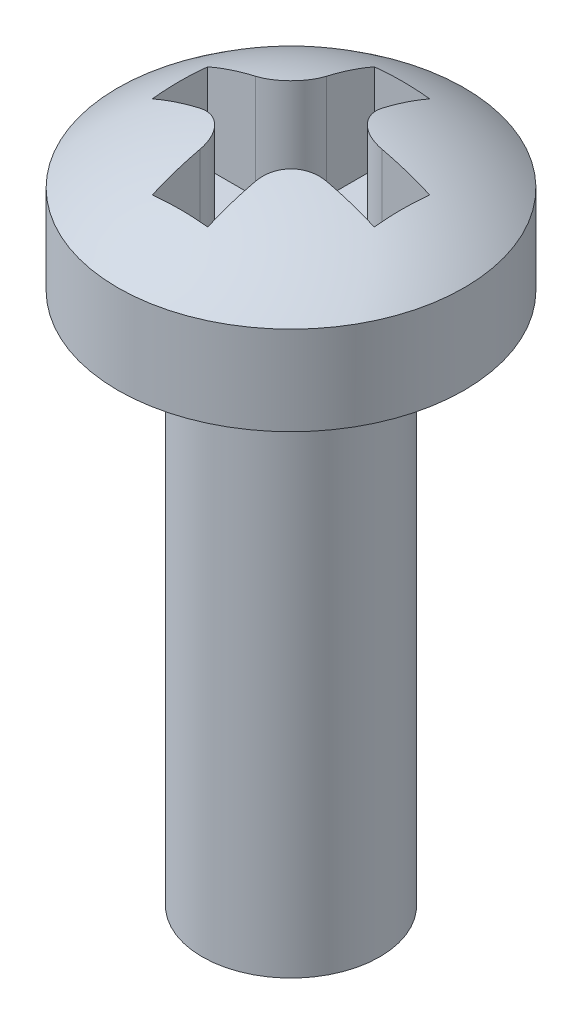
from build123d import *

# Parameters (mm, degrees)
SKETCH1_R           = 2
BOSS_EXTRUDE1_DEPTH = 12
SKETCH5_R           = 3.9
BOSS_EXTRUDE2_DEPTH = 2
CUT_EXTRUDE1_DEPTH  = 2.545952


with BuildPart() as part:
    # Sketch1 → Boss-Extrude1 (new body)
    with BuildSketch(Plane(origin=(0, 0, 0), x_dir=(1, 0, 0), z_dir=(0, 1, 0))):
        Circle(SKETCH1_R)
    extrude(amount=BOSS_EXTRUDE1_DEPTH)

    # Sketch5 → Boss-Extrude2 (add)
    with BuildSketch(Plane(origin=(0, 12, 0), x_dir=(1, 0, 0), z_dir=(0, 1, 0))):
        Circle(SKETCH5_R)
    extrude(amount=BOSS_EXTRUDE2_DEPTH)

    # Sketch6 → Revolve1 (revolve)
    with BuildSketch(Plane(origin=(0, 0, 0), x_dir=(0, 0, -1), z_dir=(1, 0, 0))):
        with BuildLine():
            Line((0, 15.345951573), (0, 14))
            Line((0, 14), (3.9, 14))
            ThreePointArc((3.9, 14), (2.062861219, 15), (0, 15.345951573))
        make_face()
    revolve(axis=Axis((0, 15.345951573, 0), (0, -1, 0)))

    # Sketch7 → Cut-Extrude1 (cut)
    with BuildSketch(Plane(origin=(0, 15.345951573, 0), x_dir=(1, 0, 0), z_dir=(0, 1, 0))):
        with BuildLine():
            Line((-2.5, -0.625), (-1.425, -0.625))
            ThreePointArc((-1.425, -0.625), (-0.859314575, -0.859314575), (-0.625, -1.425))
            Line((-0.625, -1.425), (-0.625, -2.5))
            Line((-0.625, -2.5), (0.625, -2.5))
            Line((0.625, -2.5), (0.625, -1.425))
            ThreePointArc((0.625, -1.425), (0.859314575, -0.859314575), (1.425, -0.625))
            Line((1.425, -0.625), (2.5, -0.625))
            Line((2.5, -0.625), (2.5, 0.625))
            Line((2.5, 0.625), (1.425, 0.625))
            ThreePointArc((1.425, 0.625), (0.859314575, 0.859314575), (0.625, 1.425))
            Line((0.625, 1.425), (0.625, 2.5))
            Line((0.625, 2.5), (-0.625, 2.5))
            Line((-0.625, 2.5), (-0.625, 1.425))
            ThreePointArc((-0.625, 1.425), (-0.859314575, 0.859314575), (-1.425, 0.625))
            Line((-1.425, 0.625), (-2.5, 0.625))
            Line((-2.5, 0.625), (-2.5, -0.625))
        make_face()
    extrude(amount=-CUT_EXTRUDE1_DEPTH, mode=Mode.SUBTRACT)


solid = part.part
